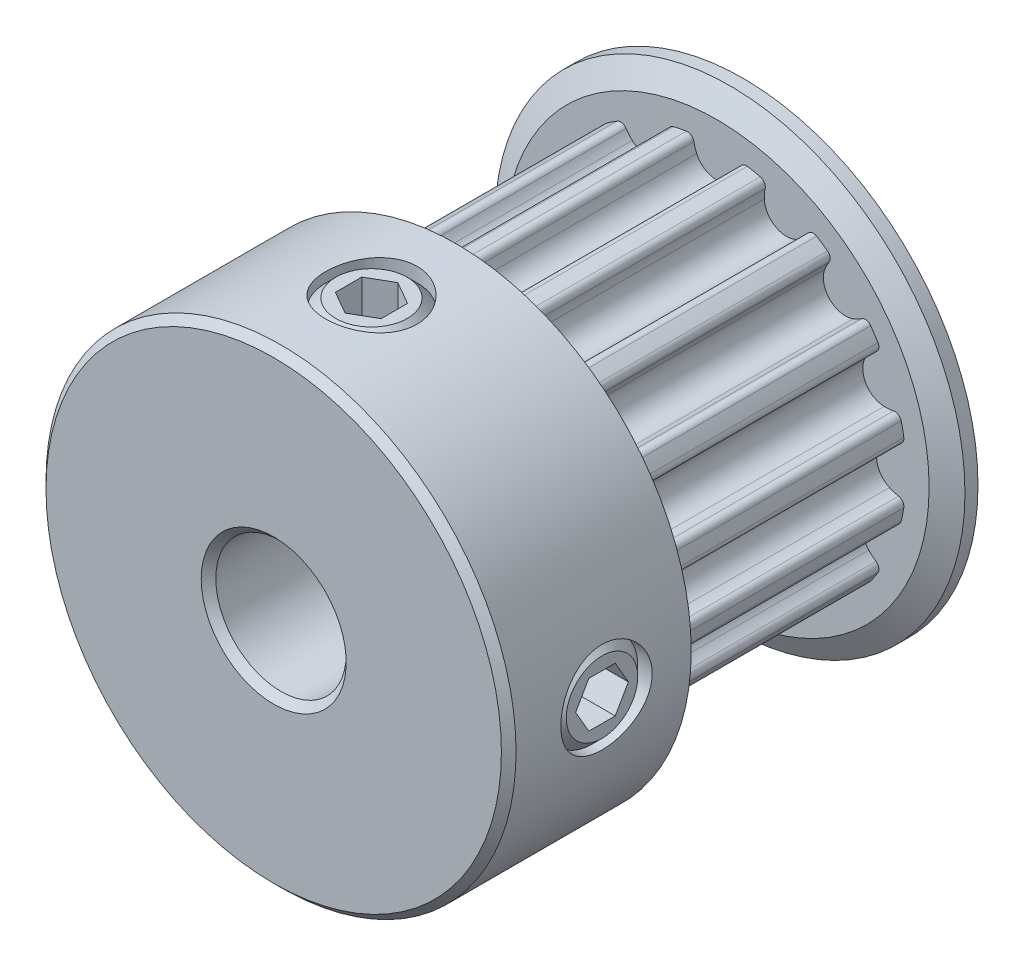
from build123d import *

# Parameters (mm, degrees)
CUT_EXTRUDE1_START = 1.5
CUT_EXTRUDE1_DEPTH = 9.5
CIRPATTERN1_COUNT  = 16
SKETCH4_R          = 1.7526
CUT_EXTRUDE2_DEPTH = 16.605782582
CUT_EXTRUDE3_DEPTH = 1.31445
CIRPATTERN3_COUNT  = 2
CIRPATTERN3_ANGLE  = 90
CHAMFER1_SIZE      = 0.28075


with BuildPart() as part:
    # Sketch2 → Revolve1 (revolve)
    with BuildSketch(Plane(origin=(0, 0, 0), x_dir=(0, 0, -1), z_dir=(1, 0, 0)), mode=Mode.PRIVATE) as revolve1_sk:
        Polygon((-9, 2.5), (9, 2.5), (9, 9.015), (8.5, 9.015), (8, 8.13975), (8, 7.2645), (-1.5, 7.2645), (-1.5, 8.13975), (-2, 9.015), (-9, 9.015), align=None)
    revolve(revolve1_sk.sketch.rotate(Axis((0, 0, 9), (0, 0, -1)), 90), axis=Axis((0, 0, 9), (0, 0, -1)))

    # Sketch3 → Cut-Extrude1 (cut)
    with BuildSketch(Plane.XY.offset(CUT_EXTRUDE1_START)):
        with BuildLine():
            Line((3.757926927, 9.015), (-3.757926927, 9.015))
            Line((-3.757926927, 9.015), (-2.795101196, 6.705249403))
            ThreePointArc((-2.795101196, 6.705249403), (-1.995846132, 6.984952288), (-1.169472895, 7.169748489))
            ThreePointArc((-1.169472895, 7.169748489), (-0.985767742, 7.127751824), (-0.883573242, 6.969424355))
            ThreePointArc((-0.883573242, 6.969424355), (-0.839120956, 6.792881518), (-0.773880597, 6.622919538))
            ThreePointArc((-0.773880597, 6.622919538), (0, 6.1245), (0.773880597, 6.622919538))
            ThreePointArc((0.773880597, 6.622919538), (0.839120956, 6.792881518), (0.883573242, 6.969424355))
            ThreePointArc((0.883573242, 6.969424355), (0.985767742, 7.127751824), (1.169472895, 7.169748489))
            ThreePointArc((1.169472895, 7.169748489), (1.995846132, 6.984952288), (2.795101196, 6.705249403))
            Line((2.795101196, 6.705249403), (3.757926927, 9.015))
        make_face()
    cut_extrude1 = extrude(amount=-CUT_EXTRUDE1_DEPTH, mode=Mode.SUBTRACT)

    # CirPattern1: Cut-Extrude1 ×16 about axis
    cirpattern1_axis = Axis((0, 0, 0), (0, 0, 1))
    for i in range(1, CIRPATTERN1_COUNT):
        add(cut_extrude1.rotate(cirpattern1_axis, i * 360 / CIRPATTERN1_COUNT), mode=Mode.SUBTRACT)

    # Sketch4 → Cut-Extrude2 (cut, through all)
    with BuildSketch(Plane(origin=(0, 0, 0), x_dir=(0, -1, 0), z_dir=(1, 0, 0))):
        with Locations(Location((0, -5.25, 0), (0, 0, 270))):
            Circle(SKETCH4_R)
    cut_extrude2 = extrude(amount=CUT_EXTRUDE2_DEPTH, mode=Mode.SUBTRACT)

    # Sketch5 → Revolve2 (revolve)
    with BuildSketch(Plane.XY.offset(5.25), mode=Mode.PRIVATE) as revolve2_sk:
        Polygon((2.5, -1.3716), (2.5, 0), (8.842998261, 0), (8.842998261, -1.3716), (8.461998261, -1.7526), (2.881, -1.7526), align=None)
    revolve2 = revolve(revolve2_sk.sketch.rotate(Axis((2.5, 0, 5.25), (1, 0, 0)), 270), axis=Axis((2.5, 0, 5.25), (1, 0, 0)))

    # Sketch6 → Cut-Extrude3 (cut)
    with BuildSketch(Plane(origin=(8.842998261, 5.384140679, 0), x_dir=(0, -1, 0), z_dir=(-1, 0, 0))):
        Polygon((5.384140679, 6.261864082), (4.507840679, 5.755932041), (4.507840679, 4.744067959), (5.384140679, 4.238135918), (6.260440679, 4.744067959), (6.260440679, 5.755932041), align=None)
    cut_extrude3 = extrude(amount=CUT_EXTRUDE3_DEPTH, mode=Mode.SUBTRACT)

    # CirPattern3: Cut-Extrude2, Revolve2, Cut-Extrude3 ×2 about axis
    cirpattern3_axis = Axis((0, 0, 0), (0, 0, 1))
    add([cut_extrude2.rotate(cirpattern3_axis, i * CIRPATTERN3_ANGLE / (CIRPATTERN3_COUNT - 1)) for i in range(1, CIRPATTERN3_COUNT)], mode=Mode.SUBTRACT)
    add([revolve2.rotate(cirpattern3_axis, i * CIRPATTERN3_ANGLE / (CIRPATTERN3_COUNT - 1)) for i in range(1, CIRPATTERN3_COUNT)])
    add([cut_extrude3.rotate(cirpattern3_axis, i * CIRPATTERN3_ANGLE / (CIRPATTERN3_COUNT - 1)) for i in range(1, CIRPATTERN3_COUNT)], mode=Mode.SUBTRACT)

    # Chamfer1
    chamfer1_edges = [part.edges().sort_by_distance(p)[0] for p in [
        (-2.5, 0, 9),
        (-9.015, 0, 9),
    ]]
    chamfer(chamfer1_edges, length=CHAMFER1_SIZE)


solid = part.part
